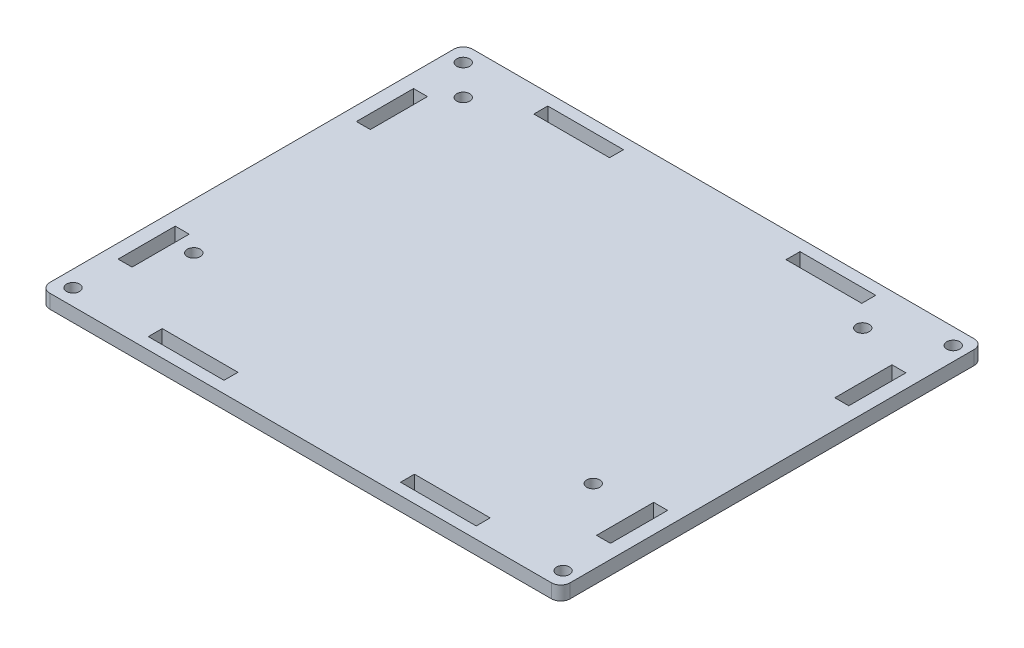
from build123d import *

# Parameters (mm, degrees)
CROQUIS1_W              = 16.3
CROQUIS1_H              = 3
CROQUIS1_W_2            = 3
CROQUIS1_H_2            = 12.3
SALIENTE_EXTRUIR1_DEPTH = 3
CORTAR_EXTRUIR1_REACH   = 5
CROQUIS2_R              = 1.4
CORTAR_EXTRUIR2_REACH   = 5
CROQUIS3_R              = 1.4


with BuildPart() as part:
    # Croquis1 → Saliente-Extruir1 (new body)
    with BuildSketch(Plane(origin=(0, 0, 0), x_dir=(1, 0, 0), z_dir=(0, 1, 0))):
        with BuildLine():
            Line((-54, 45.5), (54, 45.5))
            ThreePointArc((54, 45.5), (55.414213562, 44.914213562), (56, 43.5))
            Line((56, 43.5), (56, -43.5))
            ThreePointArc((56, -43.5), (55.414213562, -44.914213562), (54, -45.5))
            Line((54, -45.5), (-54, -45.5))
            ThreePointArc((-54, -45.5), (-55.414213562, -44.914213562), (-56, -43.5))
            Line((-56, -43.5), (-56, 43.5))
            ThreePointArc((-56, 43.5), (-55.414213562, 44.914213562), (-54, 45.5))
        make_face()
        with Locations((-27.15, 41.5)):
            Rectangle(CROQUIS1_W, CROQUIS1_H, mode=Mode.SUBTRACT)
        with Locations((27.15, 41.5)):
            Rectangle(CROQUIS1_W, CROQUIS1_H, mode=Mode.SUBTRACT)
        with Locations((-27.15, -41.5)):
            Rectangle(CROQUIS1_W, CROQUIS1_H, mode=Mode.SUBTRACT)
        with Locations((27.15, -41.5)):
            Rectangle(CROQUIS1_W, CROQUIS1_H, mode=Mode.SUBTRACT)
        with Locations((51.5, 25.65)):
            Rectangle(CROQUIS1_W_2, CROQUIS1_H_2, mode=Mode.SUBTRACT)
        with Locations((51.5, -25.65)):
            Rectangle(CROQUIS1_W_2, CROQUIS1_H_2, mode=Mode.SUBTRACT)
        with Locations((-51.5, 25.65)):
            Rectangle(CROQUIS1_W_2, CROQUIS1_H_2, mode=Mode.SUBTRACT)
        with Locations((-51.5, -25.65)):
            Rectangle(CROQUIS1_W_2, CROQUIS1_H_2, mode=Mode.SUBTRACT)
    extrude(amount=SALIENTE_EXTRUIR1_DEPTH)

    # Croquis2 → Cortar-Extruir1 (cut, up to next)
    with BuildSketch(Plane.XZ, mode=Mode.PRIVATE) as cortar_extruir1_sk1:
        with Locations((53, -42)):
            Circle(CROQUIS2_R)
    cortar_extruir1_tool1 = extrude(cortar_extruir1_sk1.sketch, amount=-CORTAR_EXTRUIR1_REACH, mode=Mode.PRIVATE) & part.part
    add(cortar_extruir1_tool1.solids().sort_by_distance((53, 0, -42))[0], mode=Mode.SUBTRACT)
    # Croquis2 → Cortar-Extruir1 (cut, up to next)
    with BuildSketch(Plane.XZ, mode=Mode.PRIVATE) as cortar_extruir1_sk2:
        with Locations((-52.5, -42)):
            Circle(CROQUIS2_R)
    cortar_extruir1_tool2 = extrude(cortar_extruir1_sk2.sketch, amount=-CORTAR_EXTRUIR1_REACH, mode=Mode.PRIVATE) & part.part
    add(cortar_extruir1_tool2.solids().sort_by_distance((-52.5, 0, -42))[0], mode=Mode.SUBTRACT)
    # Croquis2 → Cortar-Extruir1 (cut, up to next)
    with BuildSketch(Plane.XZ, mode=Mode.PRIVATE) as cortar_extruir1_sk3:
        with Locations((-52.5, 42)):
            Circle(CROQUIS2_R)
    cortar_extruir1_tool3 = extrude(cortar_extruir1_sk3.sketch, amount=-CORTAR_EXTRUIR1_REACH, mode=Mode.PRIVATE) & part.part
    add(cortar_extruir1_tool3.solids().sort_by_distance((-52.5, 0, 42))[0], mode=Mode.SUBTRACT)
    # Croquis2 → Cortar-Extruir1 (cut, up to next)
    with BuildSketch(Plane.XZ, mode=Mode.PRIVATE) as cortar_extruir1_sk4:
        with Locations((53, 42)):
            Circle(CROQUIS2_R)
    cortar_extruir1_tool4 = extrude(cortar_extruir1_sk4.sketch, amount=-CORTAR_EXTRUIR1_REACH, mode=Mode.PRIVATE) & part.part
    add(cortar_extruir1_tool4.solids().sort_by_distance((53, 0, 42))[0], mode=Mode.SUBTRACT)

    # Croquis3 → Cortar-Extruir2 (cut, up to next)
    with BuildSketch(Plane(origin=(0, 0, 0), x_dir=(1, 0, 0), z_dir=(0, 1, 0)), mode=Mode.PRIVATE) as cortar_extruir2_sk1:
        with Locations((40, -22.5)):
            Circle(CROQUIS3_R)
    cortar_extruir2_tool1 = extrude(cortar_extruir2_sk1.sketch, amount=CORTAR_EXTRUIR2_REACH, mode=Mode.PRIVATE) & part.part
    add(cortar_extruir2_tool1.solids().sort_by_distance((40, 0, 22.5))[0], mode=Mode.SUBTRACT)
    # Croquis3 → Cortar-Extruir2 (cut, up to next)
    with BuildSketch(Plane(origin=(0, 0, 0), x_dir=(1, 0, 0), z_dir=(0, 1, 0)), mode=Mode.PRIVATE) as cortar_extruir2_sk2:
        with Locations((40, 35.5)):
            Circle(CROQUIS3_R)
    cortar_extruir2_tool2 = extrude(cortar_extruir2_sk2.sketch, amount=CORTAR_EXTRUIR2_REACH, mode=Mode.PRIVATE) & part.part
    add(cortar_extruir2_tool2.solids().sort_by_distance((40, 0, -35.5))[0], mode=Mode.SUBTRACT)
    # Croquis3 → Cortar-Extruir2 (cut, up to next)
    with BuildSketch(Plane(origin=(0, 0, 0), x_dir=(1, 0, 0), z_dir=(0, 1, 0)), mode=Mode.PRIVATE) as cortar_extruir2_sk3:
        with Locations((-46, 35.5)):
            Circle(CROQUIS3_R)
    cortar_extruir2_tool3 = extrude(cortar_extruir2_sk3.sketch, amount=CORTAR_EXTRUIR2_REACH, mode=Mode.PRIVATE) & part.part
    add(cortar_extruir2_tool3.solids().sort_by_distance((-46, 0, -35.5))[0], mode=Mode.SUBTRACT)
    # Croquis3 → Cortar-Extruir2 (cut, up to next)
    with BuildSketch(Plane(origin=(0, 0, 0), x_dir=(1, 0, 0), z_dir=(0, 1, 0)), mode=Mode.PRIVATE) as cortar_extruir2_sk4:
        with Locations((-46, -22.5)):
            Circle(CROQUIS3_R)
    cortar_extruir2_tool4 = extrude(cortar_extruir2_sk4.sketch, amount=CORTAR_EXTRUIR2_REACH, mode=Mode.PRIVATE) & part.part
    add(cortar_extruir2_tool4.solids().sort_by_distance((-46, 0, 22.5))[0], mode=Mode.SUBTRACT)


solid = part.part
